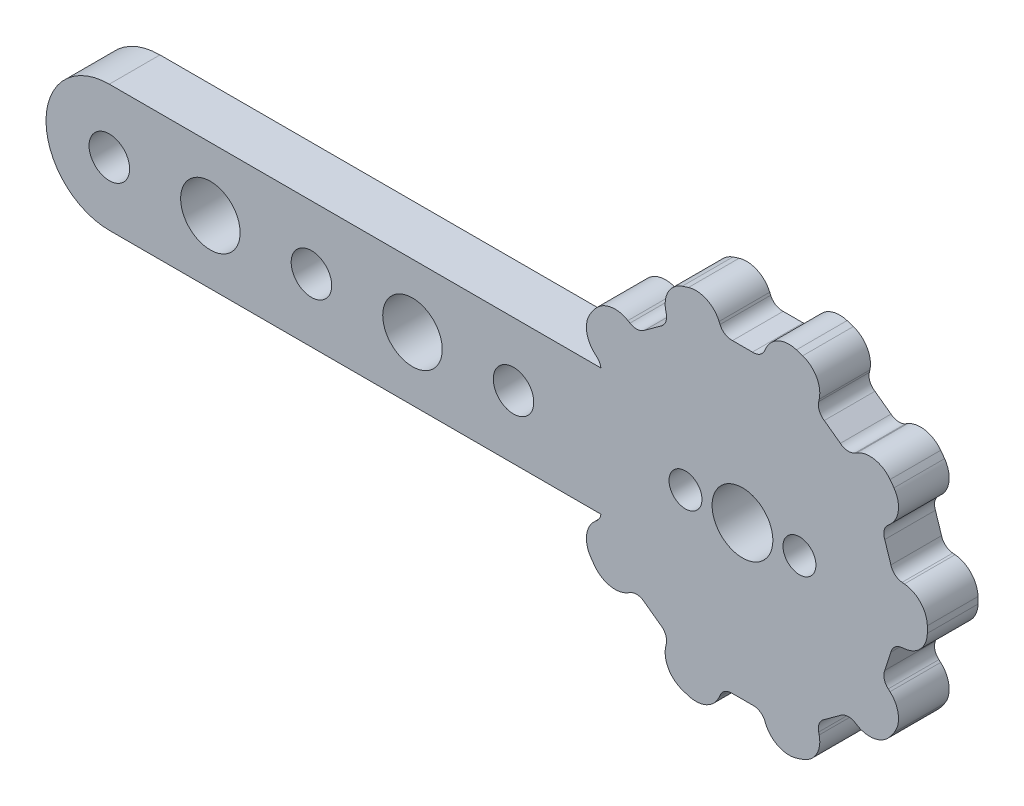
from build123d import *

# Parameters (mm, degrees)
SKETCH1_R           = 2.4
SKETCH1_R_2         = 1.3
BOSS_EXTRUDE1_DEPTH = 4
BOSS_EXTRUDE2_START = -4
SKETCH2_R           = 1.6
SKETCH2_R_2         = 2.35
BOSS_EXTRUDE2_DEPTH = 4
FILLET1_R           = 2


with BuildPart() as part:
    # Sketch1 → Boss-Extrude1 (new body)
    with BuildSketch(Plane.XY):
        with BuildLine():
            Line((6.458174517, 10.22648556), (7.730280052, 9.302246788))
            ThreePointArc((7.730280052, 9.302246788), (8.293531937, 9.074228241), (8.884801529, 9.214390334))
            ThreePointArc((8.884801529, 9.214390334), (9.700788202, 9.679292345), (10.537793023, 10.105192636))
            ThreePointArc((10.537793023, 10.105192636), (11.811648118, 8.581664683), (12.866966432, 6.899360466))
            ThreePointArc((12.866966432, 6.899360466), (12.203262471, 6.234932004), (11.508960635, 5.602545185))
            ThreePointArc((11.508960635, 5.602545185), (11.192946211, 5.083526854), (11.235750332, 4.477380873))
            Line((11.235750332, 4.477380873), (11.721651409, 2.981931127))
            ThreePointArc((11.721651409, 2.981931127), (12.043305816, 2.466389096), (12.604038176, 2.232243064))
            ThreePointArc((12.604038176, 2.232243064), (13.537447807, 2.12873176), (14.464936842, 1.981313243))
            ThreePointArc((14.464936842, 1.981313243), (14.6, 0), (14.464936842, -1.981313243))
            ThreePointArc((14.464936842, -1.981313243), (13.537447807, -2.12873176), (12.604038176, -2.232243064))
            ThreePointArc((12.604038176, -2.232243064), (12.043305816, -2.466389096), (11.721651409, -2.981931127))
            Line((11.721651409, -2.981931127), (11.235750332, -4.477380873))
            ThreePointArc((11.235750332, -4.477380873), (11.192946211, -5.083526854), (11.508960635, -5.602545185))
            ThreePointArc((11.508960635, -5.602545185), (12.203262471, -6.234932004), (12.866966432, -6.899360466))
            ThreePointArc((12.866966432, -6.899360466), (11.811648118, -8.581664683), (10.537793023, -10.105192636))
            ThreePointArc((10.537793023, -10.105192636), (9.700788202, -9.679292345), (8.884801529, -9.214390334))
            ThreePointArc((8.884801529, -9.214390334), (8.293531937, -9.074228241), (7.730280052, -9.302246788))
            Line((7.730280052, -9.302246788), (6.458174517, -10.22648556))
            ThreePointArc((6.458174517, -10.22648556), (6.067261587, -10.691708329), (6.017851306, -11.297351596))
            ThreePointArc((6.017851306, -11.297351596), (6.207845644, -12.21706366), (6.354252177, -13.144712978))
            ThreePointArc((6.354252177, -13.144712978), (4.511648118, -13.885425138), (2.585570436, -14.369231904))
            ThreePointArc((2.585570436, -14.369231904), (2.158757221, -13.532692241), (1.771872682, -12.676953681))
            ThreePointArc((1.771872682, -12.676953681), (1.375910744, -12.216020619), (0.786204458, -12.069420349))
            Line((0.786204458, -12.069420349), (-0.786204458, -12.069420349))
            ThreePointArc((-0.786204458, -12.069420349), (-1.375910744, -12.216020619), (-1.771872682, -12.676953681))
            ThreePointArc((-1.771872682, -12.676953681), (-2.158757221, -13.532692241), (-2.585570436, -14.369231904))
            ThreePointArc((-2.585570436, -14.369231904), (-4.511648118, -13.885425138), (-6.354252177, -13.144712978))
            ThreePointArc((-6.354252177, -13.144712978), (-6.207845644, -12.21706366), (-6.017851306, -11.297351596))
            ThreePointArc((-6.017851306, -11.297351596), (-6.067261587, -10.691708329), (-6.458174517, -10.22648556))
            Line((-6.458174517, -10.22648556), (-7.730280052, -9.302246788))
            ThreePointArc((-7.730280052, -9.302246788), (-8.293531937, -9.074228241), (-8.884801529, -9.214390334))
            ThreePointArc((-8.884801529, -9.214390334), (-9.700788202, -9.679292345), (-10.537793023, -10.105192636))
            ThreePointArc((-10.537793023, -10.105192636), (-11.811648118, -8.581664683), (-12.866966432, -6.899360466))
            ThreePointArc((-12.866966432, -6.899360466), (-12.203262471, -6.234932004), (-11.508960635, -5.602545185))
            ThreePointArc((-11.508960635, -5.602545185), (-11.192946211, -5.083526854), (-11.235750332, -4.477380873))
            Line((-11.235750332, -4.477380873), (-11.721651409, -2.981931127))
            ThreePointArc((-11.721651409, -2.981931127), (-12.043305816, -2.466389096), (-12.604038176, -2.232243064))
            ThreePointArc((-12.604038176, -2.232243064), (-13.537447807, -2.12873176), (-14.464936842, -1.981313243))
            ThreePointArc((-14.464936842, -1.981313243), (-14.6, 0), (-14.464936842, 1.981313243))
            ThreePointArc((-14.464936842, 1.981313243), (-13.537447807, 2.12873176), (-12.604038176, 2.232243064))
            ThreePointArc((-12.604038176, 2.232243064), (-12.043305816, 2.466389096), (-11.721651409, 2.981931127))
            Line((-11.721651409, 2.981931127), (-11.235750332, 4.477380873))
            ThreePointArc((-11.235750332, 4.477380873), (-11.192946211, 5.083526854), (-11.508960635, 5.602545185))
            ThreePointArc((-11.508960635, 5.602545185), (-12.203262471, 6.234932004), (-12.866966432, 6.899360466))
            ThreePointArc((-12.866966432, 6.899360466), (-11.811648118, 8.581664683), (-10.537793023, 10.105192636))
            ThreePointArc((-10.537793023, 10.105192636), (-9.700788202, 9.679292345), (-8.884801529, 9.214390334))
            ThreePointArc((-8.884801529, 9.214390334), (-8.293531937, 9.074228241), (-7.730280052, 9.302246788))
            Line((-7.730280052, 9.302246788), (-6.458174517, 10.22648556))
            ThreePointArc((-6.458174517, 10.22648556), (-6.067261587, 10.691708329), (-6.017851306, 11.297351596))
            ThreePointArc((-6.017851306, 11.297351596), (-6.207845644, 12.21706366), (-6.354252177, 13.144712978))
            ThreePointArc((-6.354252177, 13.144712978), (-4.511648118, 13.885425138), (-2.585570436, 14.369231904))
            ThreePointArc((-2.585570436, 14.369231904), (-2.158757221, 13.532692241), (-1.771872682, 12.676953681))
            ThreePointArc((-1.771872682, 12.676953681), (-1.375910744, 12.216020619), (-0.786204458, 12.069420349))
            Line((-0.786204458, 12.069420349), (0.786204458, 12.069420349))
            ThreePointArc((0.786204458, 12.069420349), (1.375910744, 12.216020619), (1.771872682, 12.676953681))
            ThreePointArc((1.771872682, 12.676953681), (2.158757221, 13.532692241), (2.585570436, 14.369231904))
            ThreePointArc((2.585570436, 14.369231904), (4.511648118, 13.885425138), (6.354252177, 13.144712978))
            ThreePointArc((6.354252177, 13.144712978), (6.207845644, 12.21706366), (6.017851306, 11.297351596))
            ThreePointArc((6.017851306, 11.297351596), (6.067261587, 10.691708329), (6.458174517, 10.22648556))
        make_face()
        Circle(SKETCH1_R, mode=Mode.SUBTRACT)
        with Locations((4.5, 0)):
            Circle(SKETCH1_R_2, mode=Mode.SUBTRACT)
        with Locations((-4.5, 0)):
            Circle(SKETCH1_R_2, mode=Mode.SUBTRACT)
    extrude(amount=BOSS_EXTRUDE1_DEPTH)

    # Sketch2 → Boss-Extrude2 (add)
    with BuildSketch(Plane(origin=(0, 0, 0), x_dir=(-1, 0, 0), z_dir=(0, 0, -1)).offset(BOSS_EXTRUDE2_START)):
        with BuildLine():
            Line((9.012554802, 0), (9.012554802, 5))
            Line((9.012554802, 5), (50, 5))
            ThreePointArc((50, 5), (55, 0), (50, -5))
            Line((50, -5), (9.012554802, -5))
            Line((9.012554802, -5), (9.012554802, 0))
        make_face()
        with Locations((50, 0)):
            Circle(SKETCH2_R, mode=Mode.SUBTRACT)
        with Locations((42.02, 0)):
            Circle(SKETCH2_R_2, mode=Mode.SUBTRACT)
        with Locations((34.04, 0)):
            Circle(SKETCH2_R, mode=Mode.SUBTRACT)
        with Locations((26.06, 0)):
            Circle(SKETCH2_R_2, mode=Mode.SUBTRACT)
        with Locations((18.08, 0)):
            Circle(SKETCH2_R, mode=Mode.SUBTRACT)
    extrude(amount=BOSS_EXTRUDE2_DEPTH)

    # Fillet1
    fillet1_edges = [part.edges().sort_by_distance(p)[0] for p in [
        (-12.866966432, 6.899360466, 2),
        (-10.537793023, 10.105192636, 2),
        (-6.354252177, 13.144712978, 2),
        (-2.585570436, 14.369231904, 2),
        (2.585570436, 14.369231904, 2),
        (6.354252177, 13.144712978, 2),
        (10.537793023, 10.105192636, 2),
        (12.866966432, 6.899360466, 2),
        (14.464936842, 1.981313243, 2),
        (14.464936842, -1.981313243, 2),
        (12.866966432, -6.899360466, 2),
        (10.537793023, -10.105192636, 2),
        (6.354252177, -13.144712978, 2),
        (2.585570436, -14.369231904, 2),
        (-2.585570436, -14.369231904, 2),
        (-6.354252177, -13.144712978, 2),
        (-10.537793023, -10.105192636, 2),
        (-12.866966432, -6.899360466, 2),
    ]]
    fillet(fillet1_edges, radius=FILLET1_R)


solid = part.part
